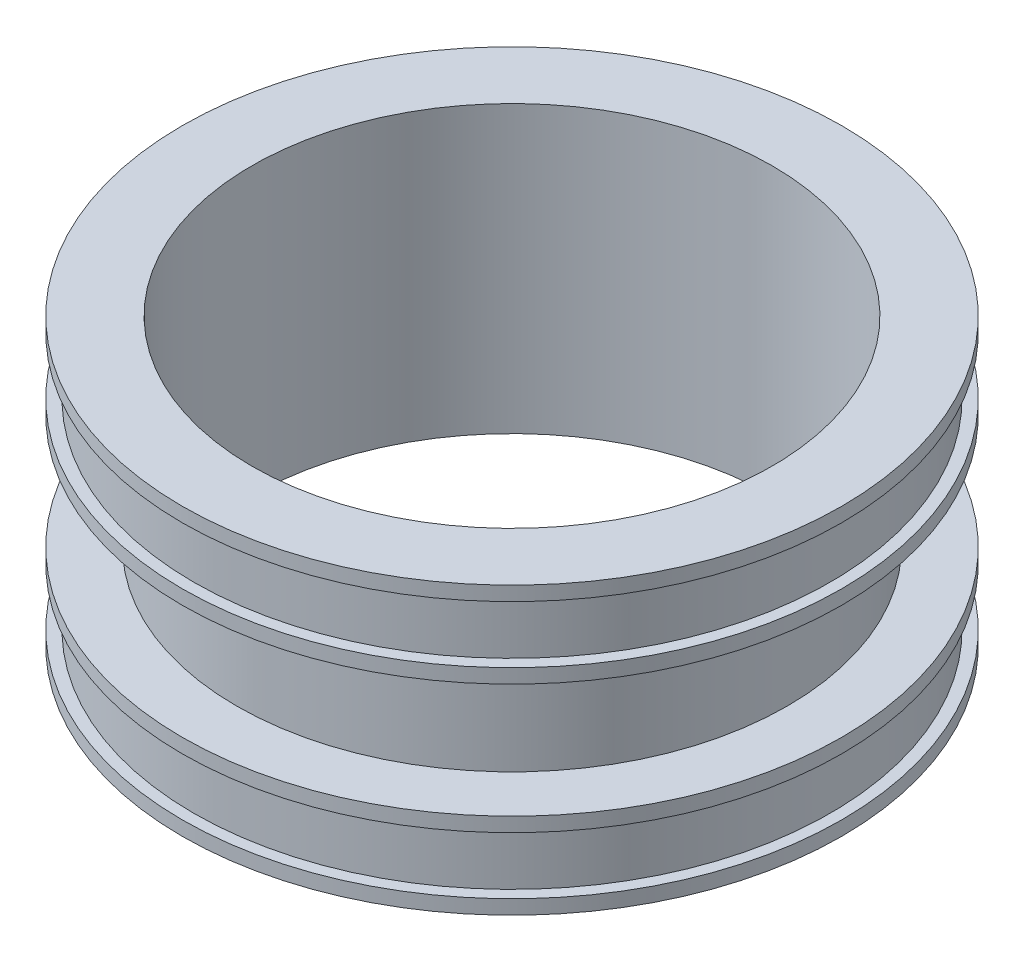
from build123d import *


with BuildPart() as part:
    # Esboço1 → Revolução1 (revolve)
    with BuildSketch(Plane.XY):
        Polygon((136.525, 150), (173, 150), (173, 142.5), (167, 142.5), (167, 112.5), (173, 112.5), (173, 105), (144.525, 105), (144.525, 45), (173, 45), (173, 37.5), (167, 37.5), (167, 7.5), (173, 7.5), (173, 0), (136.525, 0), align=None)
    revolve(axis=Axis((0, 0, 0), (0, 1, 0)))


solid = part.part
